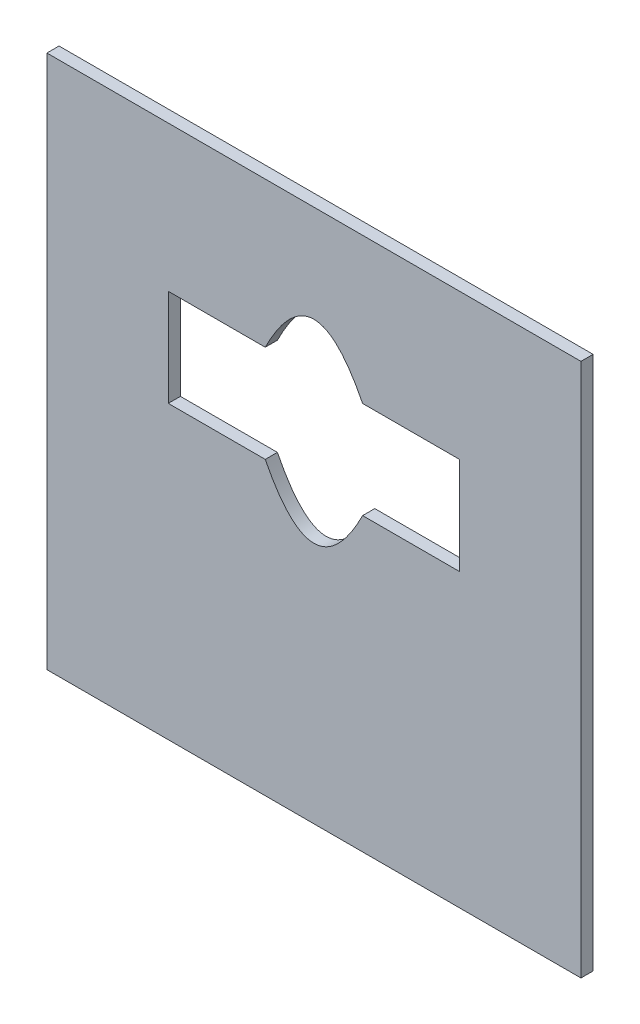
from build123d import *

# Parameters (mm, degrees)
SKETCH1_W           = 139.7
SKETCH1_H           = 139.7
BOSS_EXTRUDE1_DEPTH = 3.175


with BuildPart() as part:
    # Sketch1 → Boss-Extrude1 (new body)
    with BuildSketch(Plane.XY):
        with Locations((69.85, 69.85)):
            Rectangle(SKETCH1_W, SKETCH1_H)
        with BuildLine():
            Line((31.75, 101.6), (57.114301478, 101.6))
            add(Edge.make_bspline(
                [(57.114301478, 101.6), (69.85, 127), (82.585698522, 101.6)],
                knots=[0, 0, 0, 1, 1, 1], degree=2))
            Line((82.585698522, 101.6), (107.95, 101.6))
            Line((107.95, 101.6), (107.95, 76.2))
            Line((107.95, 76.2), (82.585698522, 76.2))
            add(Edge.make_bspline(
                [(57.114301478, 76.2), (69.85, 50.917743629), (82.585698522, 76.2)],
                knots=[0, 0, 0, 1, 1, 1], degree=2))
            Line((57.114301478, 76.2), (31.75, 76.2))
            Line((31.75, 76.2), (31.75, 101.6))
        make_face(mode=Mode.SUBTRACT)
    extrude(amount=BOSS_EXTRUDE1_DEPTH)


solid = part.part
